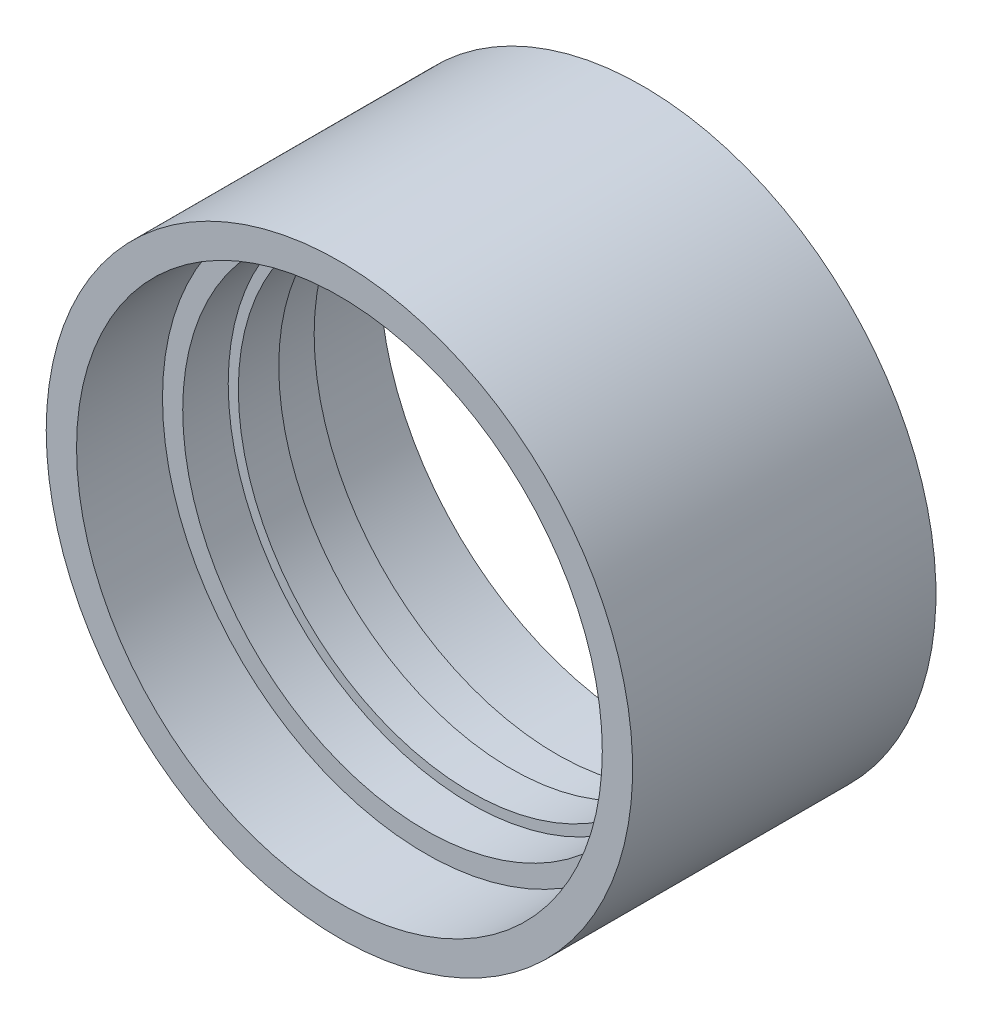
from build123d import *


with BuildPart() as part:
    # Skizze1 → Rotation1 (revolve)
    with BuildSketch(Plane(origin=(0, 0, 0), x_dir=(0, 0, -1), z_dir=(1, 0, 0))):
        Polygon((-15, 29), (15, 29), (15, 26), (6.5, 26), (6.5, 24), (2, 24), (2, 23), (-2, 23), (-2, 24), (-6.5, 24), (-6.5, 26), (-15, 26), align=None)
    revolve(axis=Axis((0, 0, -12.129217255), (0, 0, 1)))


solid = part.part
